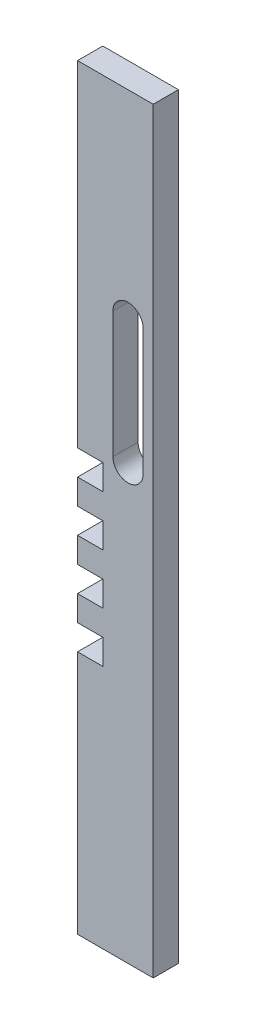
from build123d import *

# Parameters (mm, degrees)
ESQUISSE1_W                = 30
ESQUISSE1_H                = 300
BOSS_EXTRU_1_DEPTH         = 10
ESQUISSE2_W                = 10
ESQUISSE2_H                = 10
ENL_V_MAT_EXTRU_1_DEPTH    = 10
R_P_TITION_LIN_AIRE1_COUNT = 4
R_P_TITION_LIN_AIRE1_PITCH = 20
ENL_V_MAT_EXTRU_2_DEPTH    = 10


with BuildPart() as part:
    # Esquisse1 → Boss.-Extru.1 (new body)
    with BuildSketch(Plane.XY):
        with Locations((-15, 150)):
            Rectangle(ESQUISSE1_W, ESQUISSE1_H)
    extrude(amount=BOSS_EXTRU_1_DEPTH)

    # Esquisse2 → Enlèv. mat.-Extru.1 (cut)
    with BuildSketch(Plane.XY.offset(10)):
        with Locations((-25, 162)):
            Rectangle(ESQUISSE2_W, ESQUISSE2_H)
    enl_v_mat_extru_1 = extrude(amount=-ENL_V_MAT_EXTRU_1_DEPTH, mode=Mode.SUBTRACT)

    # Répétition linéaire1: Enlèv. mat.-Extru.1 ×4
    with Locations(*[(0, -i * R_P_TITION_LIN_AIRE1_PITCH, 0) for i in range(1, R_P_TITION_LIN_AIRE1_COUNT)]):
        add(enl_v_mat_extru_1, mode=Mode.SUBTRACT)

    # Esquisse3 → Enlèv. mat.-Extru.2 (cut)
    with BuildSketch(Plane.XY.offset(10)):
        with BuildLine():
            Line((-4, 171), (-4, 221))
            ThreePointArc((-4, 221), (-10, 227), (-16, 221))
            Line((-16, 221), (-16, 171))
            ThreePointArc((-16, 171), (-10, 165), (-4, 171))
        make_face()
    extrude(amount=-ENL_V_MAT_EXTRU_2_DEPTH, mode=Mode.SUBTRACT)


solid = part.part
